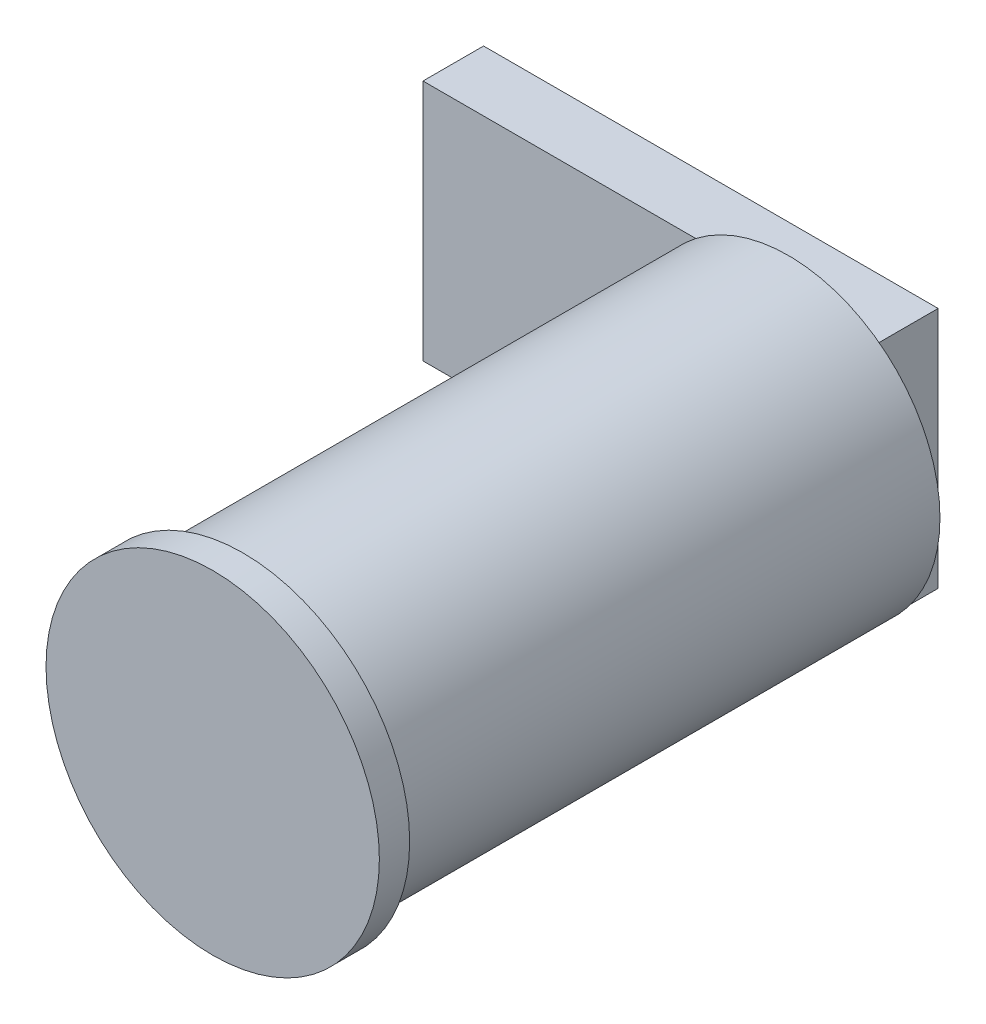
from build123d import *

# Parameters (mm, degrees)
ESQUISSE1_R        = 5.5
ESQUISSE1_R_2      = 5
BOSS_EXTRU_1_DEPTH = 1
ESQUISSE4_R        = 5
BOSS_EXTRU_2_DEPTH = 19
ESQUISSE5_W        = 15
ESQUISSE5_H        = 8.000613173
BOSS_EXTRU_3_DEPTH = 2


with BuildPart() as part:
    # Esquisse1 → Boss.-Extru.1 (new body)
    with BuildSketch(Plane.XY):
        Circle(ESQUISSE1_R)
        Circle(ESQUISSE1_R_2, mode=Mode.SUBTRACT)
    extrude(amount=-BOSS_EXTRU_1_DEPTH)

    # Esquisse4 → Boss.-Extru.2 (add)
    with BuildSketch(Plane.XY):
        Circle(ESQUISSE4_R)
    extrude(amount=-BOSS_EXTRU_2_DEPTH)

    # Esquisse5 → Boss.-Extru.3 (add)
    with BuildSketch(Plane(origin=(0, 0, -19), x_dir=(-1, 0, 0), z_dir=(0, 0, -1))):
        with Locations((4.560754253, -0.044546246)):
            Rectangle(ESQUISSE5_W, ESQUISSE5_H)
    extrude(amount=BOSS_EXTRU_3_DEPTH)


solid = part.part
